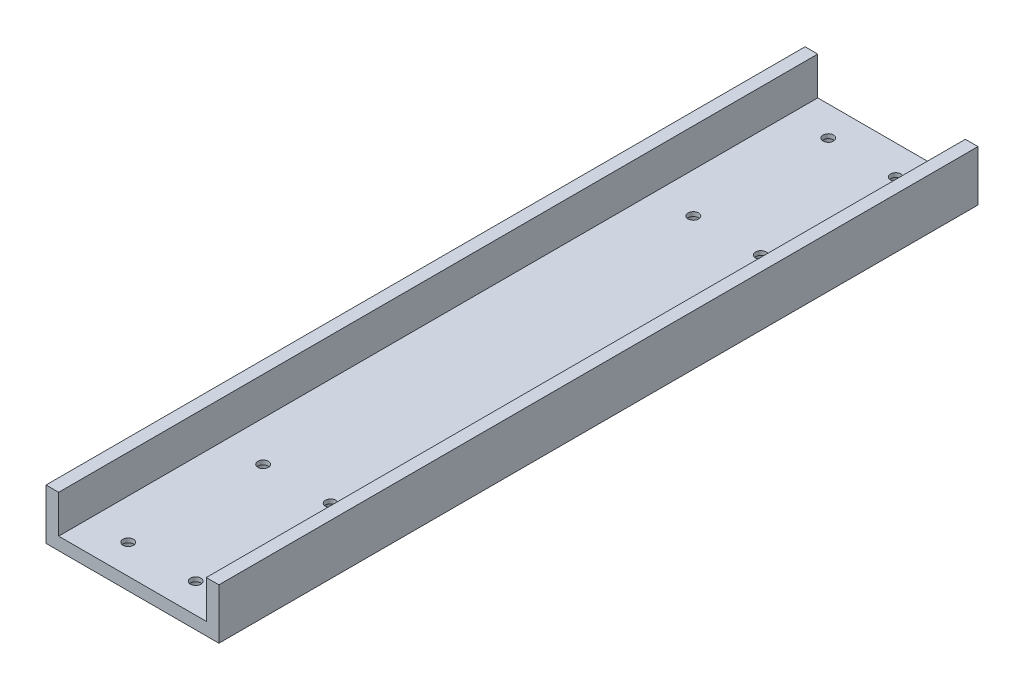
from build123d import *

# Parameters (mm, degrees)
SKETCH2_W           = 35
SKETCH2_H           = 3
BOSS_EXTRUDE1_DEPTH = 90
CUT_EXTRUDE1_START  = -13
SKETCH3_R           = 1.25
CUT_EXTRUDE1_DEPTH  = 14
SKETCH4_R           = 2.25
CUT_EXTRUDE2_DEPTH  = 2


with BuildPart() as part:
    # Sketch2 → Boss-Extrude1 (new body)
    with BuildSketch(Plane.XY):
        Polygon((17.5, 10.5), (17.5, 1.5), (17.5, -1.5), (20.5, -1.5), (20.5, 10.5), align=None)
        Rectangle(SKETCH2_W, SKETCH2_H)
        Polygon((-17.5, -1.5), (-17.5, 1.5), (-17.5, 10.5), (-20.5, 10.5), (-20.5, -1.5), align=None)
    boss_extrude1 = extrude(amount=BOSS_EXTRUDE1_DEPTH)

    # Sketch3 → Cut-Extrude1 (cut)
    with BuildSketch(Plane.XZ.offset(1.5).offset(CUT_EXTRUDE1_START)):
        with Locations((-8, 83)):
            Circle(SKETCH3_R)
        with Locations((8, 83)):
            Circle(SKETCH3_R)
        with Locations((8, 51)):
            Circle(SKETCH3_R)
        with Locations((-8, 51)):
            Circle(SKETCH3_R)
    cut_extrude1 = extrude(amount=CUT_EXTRUDE1_DEPTH, mode=Mode.SUBTRACT)

    # Sketch4 → Cut-Extrude2 (cut)
    with BuildSketch(Plane.XZ.offset(1.5)):
        with Locations((-8, 83)):
            Circle(SKETCH4_R)
        with Locations((8, 83)):
            Circle(SKETCH4_R)
        with Locations((8, 51)):
            Circle(SKETCH4_R)
        with Locations((-8, 51)):
            Circle(SKETCH4_R)
    cut_extrude2 = extrude(amount=-CUT_EXTRUDE2_DEPTH, mode=Mode.SUBTRACT)

    # Mirror1: Boss-Extrude1, Cut-Extrude1, Cut-Extrude2 across plane
    add(boss_extrude1.mirror(Plane.XY))
    add(cut_extrude1.mirror(Plane.XY), mode=Mode.SUBTRACT)
    add(cut_extrude2.mirror(Plane.XY), mode=Mode.SUBTRACT)


solid = part.part
